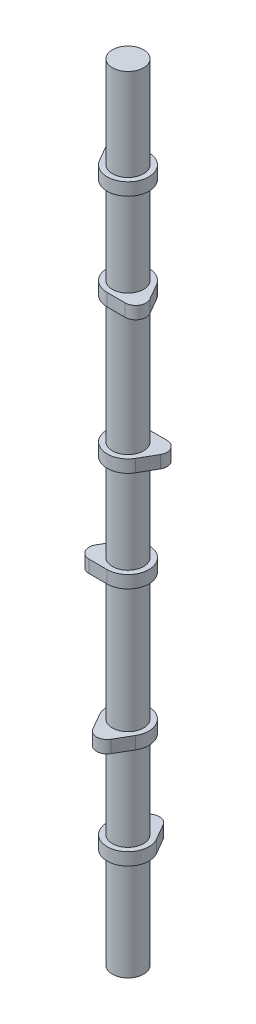
from build123d import *

# Parameters (mm, degrees)
BOSS_EXTRUDE1_DEPTH      = 3.81
BODY_MOVE_COPY2_ANGLE    = 180
BOSS_EXTRUDE2_DEPTH      = 146.05
BOSS_EXTRUDE2_DEPTH_BACK = 11.7
BOSS_EXTRUDE2_START      = -25.4
SKETCH2_R                = 9.5
LPATTERN1_COUNT          = 3
LPATTERN1_PITCH          = 146.05
BODY_MOVE_COPY3_ANGLE    = 120
BODY_MOVE_COPY4_ANGLE    = 120
SKETCH3_R                = 9.5
BOSS_EXTRUDE3_DEPTH      = 27.94


with BuildPart() as part:
    # Sketch1 → Boss-Extrude1 (new, symmetric)
    with BuildSketch(Plane(origin=(0, 0, 0), x_dir=(1, 0, 0), z_dir=(0, 1, 0))):
        with BuildLine():
            Line((-5.499261314, 15.875), (-10.998522628, 6.35))
            ThreePointArc((-10.998522628, 6.35), (0, -12.7), (10.998522628, 6.35))
            Line((10.998522628, 6.35), (5.499261314, 15.875))
            ThreePointArc((5.499261314, 15.875), (0, 19.05), (-5.499261314, 15.875))
        make_face()
    extrude(amount=BOSS_EXTRUDE1_DEPTH, both=True)


with BuildPart() as body_2:
    # Body-Move_Copy1: copy of part
    add(part.part.moved(Location((0, 60.96, 0))))


with BuildPart() as body_2_1:
    # Body-Move_Copy2: moved
    add(body_2.part.rotate(Axis((0, 0, 0), (0, 1, 0)), BODY_MOVE_COPY2_ANGLE))


with BuildPart() as part_1:
    add(part.part)

    add(body_2_1.part)  # Boss-Extrude2 merges body 2
    # Sketch2 → Boss-Extrude2 (add, two sides: drawn at the far end of the back side and taken through both)
    with BuildSketch(Plane(origin=(0, 0, 0), x_dir=(1, 0, 0), z_dir=(0, 1, 0)).offset(BOSS_EXTRUDE2_START - BOSS_EXTRUDE2_DEPTH_BACK)):
        Circle(SKETCH2_R)
    extrude(amount=BOSS_EXTRUDE2_DEPTH + BOSS_EXTRUDE2_DEPTH_BACK)


with BuildPart() as lpattern1_1:
    # LPattern1: pattern copy
    add(part_1.part.moved(Location(Vector(0, 1, 0) * (1 * LPATTERN1_PITCH))))


with BuildPart() as lpattern1_2:
    # LPattern1: pattern copy
    add(part_1.part.moved(Location(Vector(0, 1, 0) * (2 * LPATTERN1_PITCH))))


with BuildPart() as lpattern1_1_1:
    # Body-Move_Copy3: moved
    add(lpattern1_1.part.rotate(Axis((0, 0, 0), (0, 1, 0)), BODY_MOVE_COPY3_ANGLE))


with BuildPart() as lpattern1_2_1:
    # Body-Move_Copy4: moved
    add(lpattern1_2.part.rotate(Axis((0, 0, 0), (0, -1, 0)), BODY_MOVE_COPY4_ANGLE))


with BuildPart() as lpattern1_1_2:
    add(lpattern1_1_1.part)

    # Combine1: union LPattern1_2, part
    add(lpattern1_2_1.part)
    add(part_1.part)

    # Sketch3 → Boss-Extrude3 (add)
    with BuildSketch(Plane.XZ.offset(37.1)):
        Circle(SKETCH3_R)
    extrude(amount=BOSS_EXTRUDE3_DEPTH)


solid = lpattern1_1_2.part
